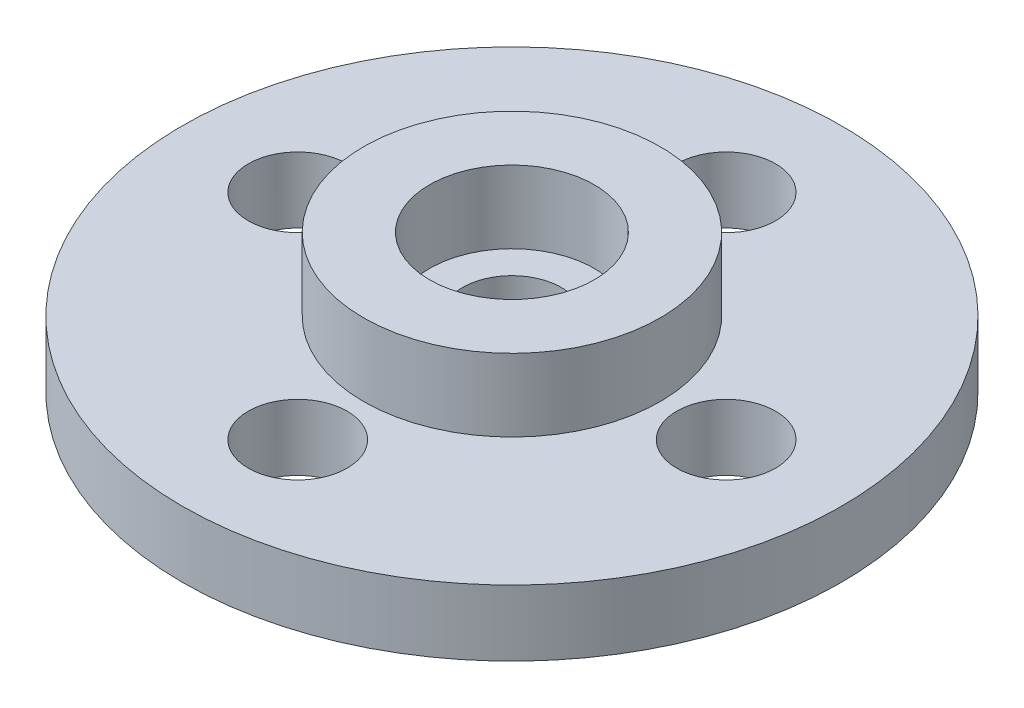
from build123d import *

# Parameters (mm, degrees)
SKETCH_1_R          = 10
SKETCH_1_R_2        = 1.5
EXTRUDE_1_DEPTH     = 4.2
SKETCH_2_R          = 10
SKETCH_2_R_2        = 4.5
SKETCH_2_R_3        = 1.5
SKETCH_2_R_4        = 2.5
CUT_EXTRUDE_1_DEPTH = 2.2


with BuildPart() as part:
    # 草图1 → 凸台-拉伸1 (new body)
    with BuildSketch(Plane(origin=(0, 0, 0), x_dir=(1, 0, 0), z_dir=(0, 1, 0))):
        Circle(SKETCH_1_R)
        with Locations((0, 6.5)):
            Circle(SKETCH_1_R_2, mode=Mode.SUBTRACT)
        with Locations((0, -6.5)):
            Circle(SKETCH_1_R_2, mode=Mode.SUBTRACT)
        with Locations((6.5, 0)):
            Circle(SKETCH_1_R_2, mode=Mode.SUBTRACT)
        with Locations((-6.5, 0)):
            Circle(SKETCH_1_R_2, mode=Mode.SUBTRACT)
        Circle(SKETCH_1_R_2, mode=Mode.SUBTRACT)
    extrude(amount=EXTRUDE_1_DEPTH)

    # 草图2 → 切除-拉伸1 (cut)
    with BuildSketch(Plane(origin=(0, 4.2, 0), x_dir=(1, 0, 0), z_dir=(0, 1, 0))):
        Circle(SKETCH_2_R)
        Circle(SKETCH_2_R_2, mode=Mode.SUBTRACT)
        with Locations((0, 6.5)):
            Circle(SKETCH_2_R_3, mode=Mode.SUBTRACT)
        with Locations((-6.5, 0)):
            Circle(SKETCH_2_R_3, mode=Mode.SUBTRACT)
        with Locations((0, -6.5)):
            Circle(SKETCH_2_R_3, mode=Mode.SUBTRACT)
        with Locations((6.5, 0)):
            Circle(SKETCH_2_R_3, mode=Mode.SUBTRACT)
        Circle(SKETCH_2_R_4)
        Circle(SKETCH_2_R_3, mode=Mode.SUBTRACT)
    extrude(amount=-CUT_EXTRUDE_1_DEPTH, mode=Mode.SUBTRACT)


solid = part.part
